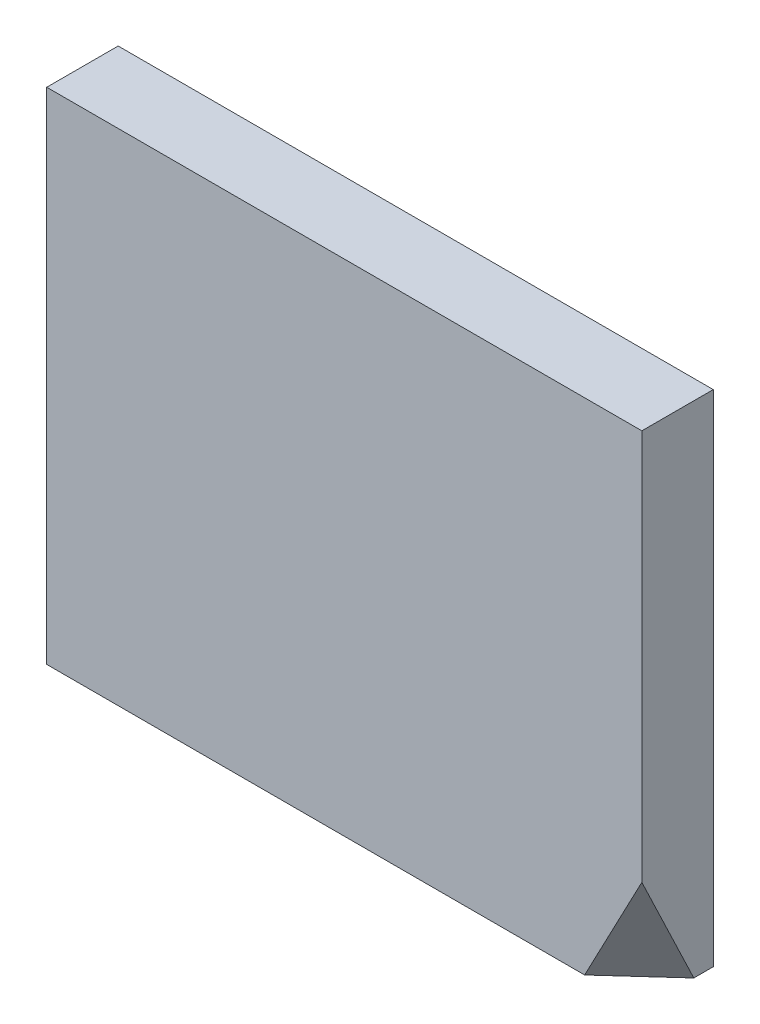
from build123d import *

# Parameters (mm, degrees)
SKETCH_1_W               = 25
SKETCH_1_H               = 21
EXTRUDE_1_DEPTH          = 3
CUT_EXTRUDE_3_DEPTH      = 19.00065745
CUT_EXTRUDE_3_DEPTH_BACK = 8.205289813


with BuildPart() as part:
    # Эскиз1 → Вытянуть1 (new body)
    with BuildSketch(Plane.XY):
        Rectangle(SKETCH_1_W, SKETCH_1_H)
    extrude(amount=EXTRUDE_1_DEPTH)

    # Эскиз5 → Вырез-Вытянуть3 (cut, two sides)
    with BuildSketch(Plane(origin=(2.320978506, -2.004481437, -3.066738831), x_dir=(0.83223631, 0.144886823, 0.535154681), z_dir=(-0.535154681, 0.462179043, 0.707106781))) as cut_extrude_3_sk:
        Polygon((41.380676695, 44.610682214), (11.149544103, -4.761591786), (8.487106278, -9.109778524), (-21.744026314, -58.482052523), (77.000521684, -118.944317707), (140.125224694, -15.85158297), align=None)
    extrude(amount=CUT_EXTRUDE_3_DEPTH, mode=Mode.SUBTRACT)
    extrude(cut_extrude_3_sk.sketch, amount=-CUT_EXTRUDE_3_DEPTH_BACK, mode=Mode.SUBTRACT)


solid = part.part
